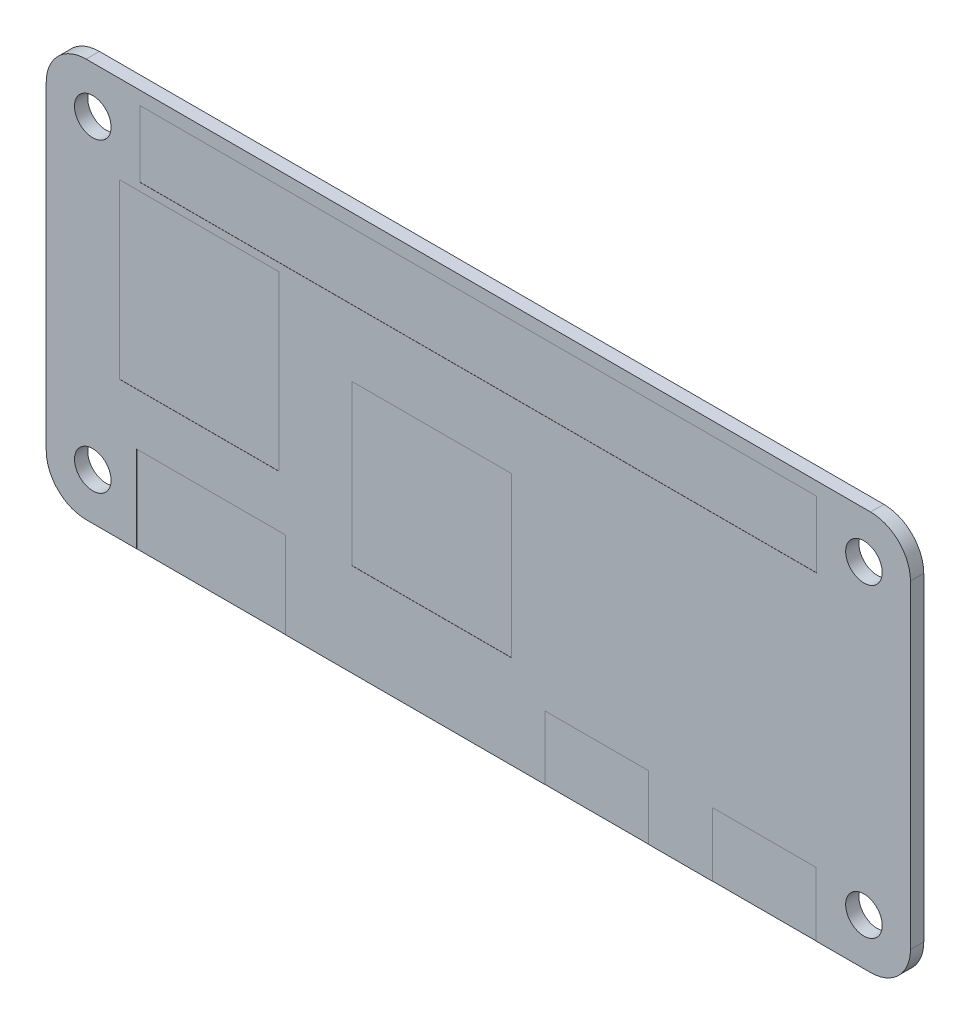
from build123d import *

# Parameters (mm, degrees)
SKETCH1_R           = 1.375
BOSS_EXTRUDE1_DEPTH = 1
SKETCH2_W           = 50.9
SKETCH2_H           = 5
SKETCH2_W_2         = 7.8
SKETCH2_H_2         = 4.8
SKETCH2_W_3         = 11.2
SKETCH2_H_3         = 6.5
SKETCH2_W_4         = 12
SKETCH2_H_4         = 13
SKETCH2_H_5         = 12
CUT_EXTRUDE1_DEPTH  = 0.01


with BuildPart() as part:
    # Sketch1 → Boss-Extrude1 (new body)
    with BuildSketch(Plane.XY):
        with BuildLine():
            Line((29.5, -15), (-29.5, -15))
            ThreePointArc((-29.5, -15), (-31.621320344, -14.121320344), (-32.5, -12))
            Line((-32.5, -12), (-32.5, 12))
            ThreePointArc((-32.5, 12), (-31.621320344, 14.121320344), (-29.5, 15))
            Line((-29.5, 15), (29.5, 15))
            ThreePointArc((29.5, 15), (31.621320344, 14.121320344), (32.5, 12))
            Line((32.5, 12), (32.5, -12))
            ThreePointArc((32.5, -12), (31.621320344, -14.121320344), (29.5, -15))
        make_face()
        with Locations((-29, 11.5)):
            Circle(SKETCH1_R, mode=Mode.SUBTRACT)
        with Locations((-29, -11.5)):
            Circle(SKETCH1_R, mode=Mode.SUBTRACT)
        with Locations((29, -11.5)):
            Circle(SKETCH1_R, mode=Mode.SUBTRACT)
        with Locations((29, 11.5)):
            Circle(SKETCH1_R, mode=Mode.SUBTRACT)
    extrude(amount=BOSS_EXTRUDE1_DEPTH)

    # Sketch2 → Cut-Extrude1 (cut)
    with BuildSketch(Plane.XY.offset(1)):
        with Locations((0, 11.5)):
            Rectangle(SKETCH2_W, SKETCH2_H)
        with Locations((21.5, -12.6)):
            Rectangle(SKETCH2_W_2, SKETCH2_H_2)
        with Locations((8.9, -12.6)):
            Rectangle(SKETCH2_W_2, SKETCH2_H_2)
        with Locations((-20.1, -11.75)):
            Rectangle(SKETCH2_W_3, SKETCH2_H_3)
        with Locations((-21, 1.9)):
            Rectangle(SKETCH2_W_4, SKETCH2_H_4)
        with Locations((-3.5, -2)):
            Rectangle(SKETCH2_W_4, SKETCH2_H_5)
    extrude(amount=-CUT_EXTRUDE1_DEPTH, mode=Mode.SUBTRACT)


solid = part.part
